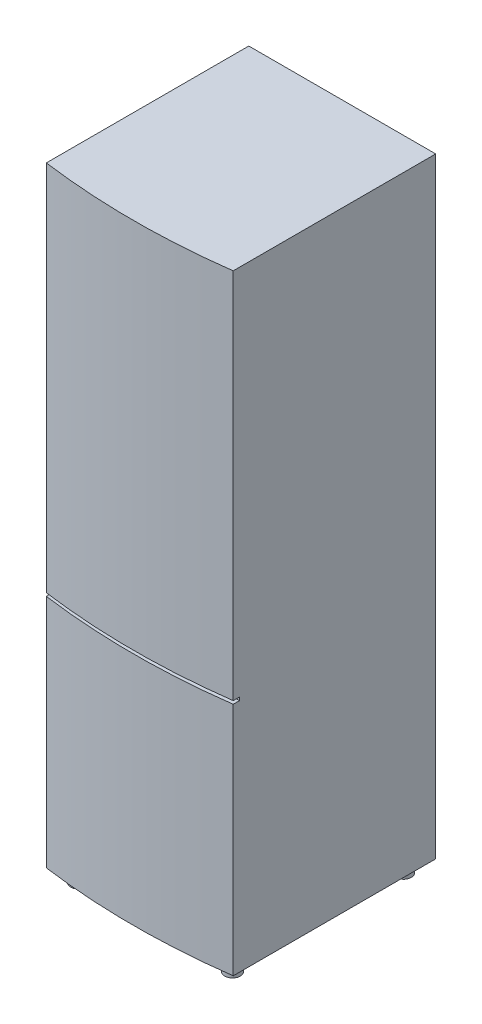
from build123d import *

# Parameters (mm, degrees)
BOSS_EXTRUDE1_DEPTH = 1960
SKETCH2_R           = 25
BOSS_EXTRUDE2_DEPTH = 40
SKETCH3_W           = 1014.048392478
SKETCH3_H           = 10
CUT_EXTRUDE1_DEPTH  = 170


with BuildPart() as part:
    # Sketch1 → Boss-Extrude1 (new body)
    with BuildSketch(Plane(origin=(0, 0, 0), x_dir=(1, 0, 0), z_dir=(0, 1, 0))):
        with BuildLine():
            Line((300, -325), (300, 325))
            Line((300, 325), (-300, 325))
            Line((-300, 325), (-300, -325))
            ThreePointArc((-300, -325), (0, -345.183114428), (300, -325))
        make_face()
    extrude(amount=BOSS_EXTRUDE1_DEPTH)

    # Sketch2 → Boss-Extrude2 (add)
    with BuildSketch(Plane.XZ):
        with Locations((-247.421181531, 274.413092674)):
            Circle(SKETCH2_R)
        with Locations((247.421181531, 274.413092674)):
            Circle(SKETCH2_R)
        with Locations((247.421181531, -274.413092674)):
            Circle(SKETCH2_R)
        with Locations((-247.421181531, -274.413092674)):
            Circle(SKETCH2_R)
    extrude(amount=BOSS_EXTRUDE2_DEPTH)

    # Sketch3 → Cut-Extrude1 (cut)
    with BuildSketch(Plane(origin=(0, 0, 475), x_dir=(-1, 0, 0), z_dir=(0, 0, -1))):
        with Locations((0, 760)):
            Rectangle(SKETCH3_W, SKETCH3_H)
    extrude(amount=CUT_EXTRUDE1_DEPTH, mode=Mode.SUBTRACT)


solid = part.part
